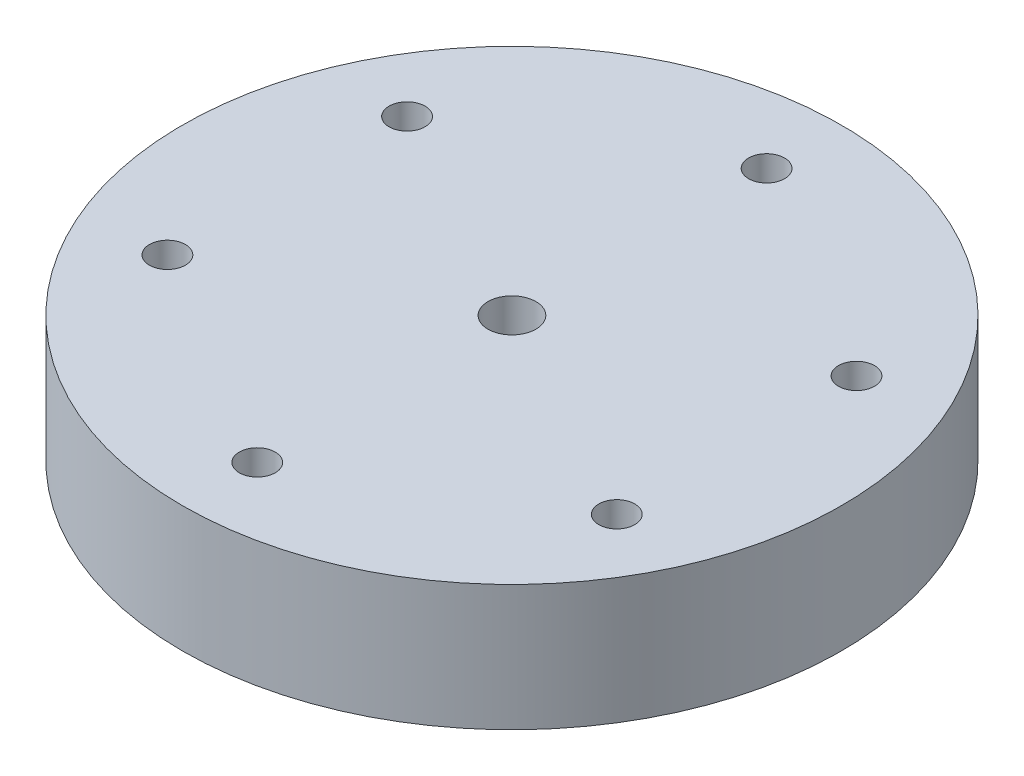
from build123d import *

# Parameters (mm, degrees)
SKETCH1_R               = 55
SKETCH1_R_2             = 4
BOSS_EXTRUDE1_DEPTH     = 21
SKETCH2_R               = 3
CUT_EXTRUDE3_DEPTH      = 22
CUT_EXTRUDE3_DEPTH_BACK = 10
SKETCH3_R               = 5
CUT_EXTRUDE4_DEPTH      = 6


with BuildPart() as part:
    # Sketch1 → Boss-Extrude1 (new body)
    with BuildSketch(Plane(origin=(0, 0, 0), x_dir=(1, 0, 0), z_dir=(0, 1, 0))):
        Circle(SKETCH1_R)
        Circle(SKETCH1_R_2, mode=Mode.SUBTRACT)
    extrude(amount=BOSS_EXTRUDE1_DEPTH)

    # Sketch2 → Cut-Extrude3 (cut, two sides)
    with BuildSketch(Plane(origin=(0, 0, 0), x_dir=(1, 0, 0), z_dir=(0, 1, 0))) as cut_extrude3_sk:
        with Locations((37.5, 20)):
            Circle(SKETCH2_R)
        with Locations((37.5, -20)):
            Circle(SKETCH2_R)
        with Locations((-37.5, -20)):
            Circle(SKETCH2_R)
        with Locations((-37.5, 20)):
            Circle(SKETCH2_R)
        with Locations((0, 42.5)):
            Circle(SKETCH2_R)
        with Locations((0, -42.5)):
            Circle(SKETCH2_R)
    extrude(amount=CUT_EXTRUDE3_DEPTH, mode=Mode.SUBTRACT)
    extrude(cut_extrude3_sk.sketch, amount=-CUT_EXTRUDE3_DEPTH_BACK, mode=Mode.SUBTRACT)

    # Sketch3 → Cut-Extrude4 (cut)
    with BuildSketch(Plane(origin=(0, 0, 0), x_dir=(1, 0, 0), z_dir=(0, 1, 0))):
        with Locations((-37.5, 20)):
            Circle(SKETCH3_R)
        with Locations((-37.5, -20)):
            Circle(SKETCH3_R)
        with Locations((37.5, 20)):
            Circle(SKETCH3_R)
        with Locations((37.5, -20)):
            Circle(SKETCH3_R)
        with Locations((0, 42.5)):
            Circle(SKETCH3_R)
        with Locations((0, -42.5)):
            Circle(SKETCH3_R)
    extrude(amount=CUT_EXTRUDE4_DEPTH, mode=Mode.SUBTRACT)


solid = part.part
